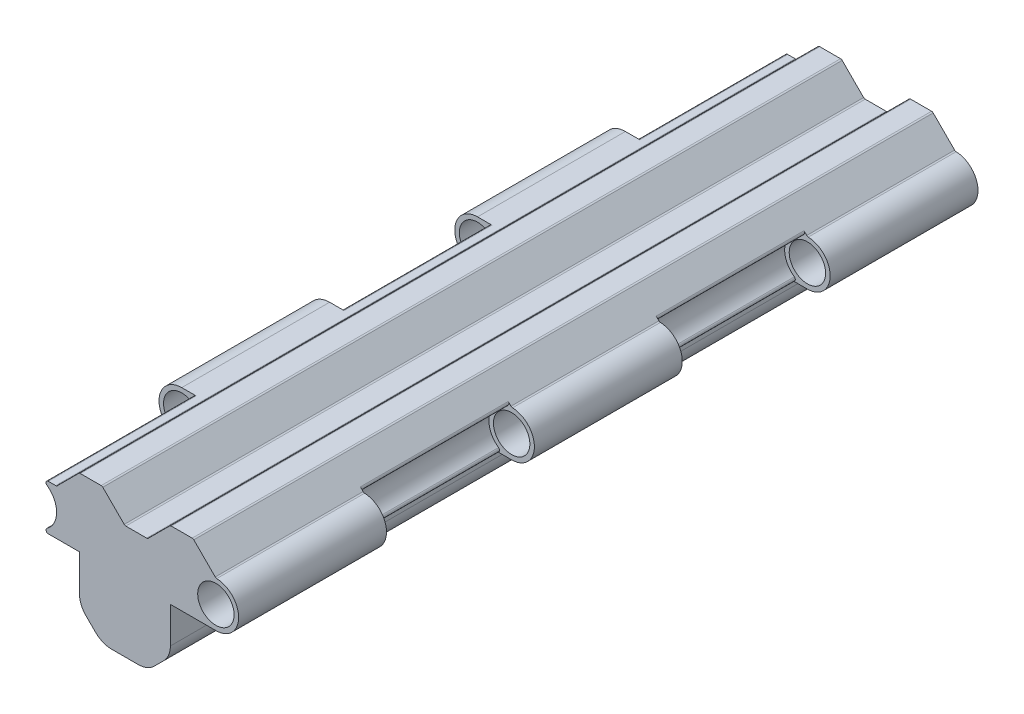
from build123d import *

# Parameters (mm, degrees)
BOSS_EXTRUDE1_DEPTH  = 32.5
CHAMFER1_SIZE        = 1
FILLET1_R            = 1
BOSS_EXTRUDE7_DEPTH  = 32.5
SKETCH3_R            = 0.9999999999999979
BOSS_EXTRUDE9_DEPTH  = 6.5
LPATTERN2_COUNT      = 3
LPATTERN2_PITCH      = 13
SKETCH5_R            = 1.0000000000000002
BOSS_EXTRUDE10_DEPTH = 6.5
LPATTERN3_COUNT      = 2
LPATTERN3_PITCH      = 13
FILLET2_R            = 0.1
M2_TAPPED_HOLE1_D    = 1.6
FILLET3_R            = 0.1


with BuildPart() as part:
    # Sketch1 → Boss-Extrude1 (new body)
    with BuildSketch(Plane.XY):
        Polygon((0, 0), (4, 0), (3.9999999999999982, 4), (-1.73e-15, 4), align=None)
    extrude(amount=BOSS_EXTRUDE1_DEPTH)

    # Chamfer1
    chamfer1_edges = [part.edges().sort_by_distance(p)[0] for p in [
        (4, 0, 16.25),
        (0, 0, 16.25),
    ]]
    chamfer(chamfer1_edges, length=CHAMFER1_SIZE)

    # Fillet1
    fillet1_edges = [part.edges().sort_by_distance(p)[0] for p in [
        (3, 0, 16.25),
        (1, 0, 16.25),
        (-4.3e-16, 1, 16.25),
        (3.9999999999999996, 1, 16.25),
    ]]
    fillet(fillet1_edges, radius=FILLET1_R)

    # Sketch2 → Boss-Extrude7 (add)
    with BuildSketch(Plane.XY.offset(32.5)):
        with BuildLine():
            Line((-1.73e-15, 3), (-2, 2.9999999999999996))
            ThreePointArc((-2, 2.9999999999999996), (-1.0000000000000009, 4), (-2, 4.999999999999999))
            Line((-2, 4.999999999999999), (-1.0000000000000009, 4.999999999999999))
            Line((-1.0000000000000009, 4.999999999999999), (-1.74e-15, 6.000000000000002))
            Line((-1.74e-15, 6.000000000000002), (1, 6))
            Line((1, 6), (2.000000000000004, 4.999999999999999))
            Line((2.000000000000004, 4.999999999999999), (3.000000000000002, 4.999999999999997))
            Line((3.000000000000002, 4.999999999999997), (4.000000000000002, 6))
            Line((4.000000000000002, 6), (5.0000000000000036, 5.999999999999998))
            Line((5.0000000000000036, 5.999999999999998), (6.000000000000008, 4.999999999999997))
            ThreePointArc((6.000000000000008, 4.999999999999997), (5.000000000000009, 3.9999999999999982), (6.000000000000008, 3))
            Line((6.000000000000008, 3), (-1.73e-15, 3))
        make_face()
    extrude(amount=-BOSS_EXTRUDE7_DEPTH)

    # Sketch3 → Boss-Extrude9 (add)
    with BuildSketch(Plane.XY.offset(32.5)):
        with Locations((6.000000000000008, 3.9999999999999982)):
            Circle(SKETCH3_R)
    boss_extrude9 = extrude(amount=-BOSS_EXTRUDE9_DEPTH)

    # LPattern2: Boss-Extrude9 ×3
    with Locations(*[(0, 0, -i * LPATTERN2_PITCH) for i in range(1, LPATTERN2_COUNT)]):
        add(boss_extrude9)

    # Sketch5 → Boss-Extrude10 (add)
    with BuildSketch(Plane.XY.offset(26.000000000000004)):
        with Locations((-2, 4)):
            Circle(SKETCH5_R)
    boss_extrude10 = extrude(amount=-BOSS_EXTRUDE10_DEPTH)

    # LPattern3: Boss-Extrude10 ×2
    with Locations(*[(0, 0, -i * LPATTERN3_PITCH) for i in range(1, LPATTERN3_COUNT)]):
        add(boss_extrude10)

    # Fillet2
    fillet2_edges = [part.edges().sort_by_distance(p)[0] for p in [
        (6.000000000000008, 4.999999999999998, 9.75),
        (6.000000000000008, 3, 9.75),
        (-2, 4.999999999999999, 29.25),
        (-2, 2.9999999999999996, 29.25),
        (-2, 4.999999999999999, 16.250000000000004),
        (-2, 2.9999999999999996, 16.250000000000004),
        (-2, 2.9999999999999996, 3.25),
        (-2, 4.999999999999999, 3.25),
        (6.000000000000008, 4.999999999999998, 22.75),
        (6.000000000000008, 3, 22.75),
    ]]
    fillet(fillet2_edges, radius=FILLET2_R)

    # M2 Tapped Hole1 (through all)
    with Locations(Plane(origin=(0, 0, 0), x_dir=(-1, 0, 0), z_dir=(0, 0, -1))):
        with Locations((-6, 4), (2, 4)):
            Hole(M2_TAPPED_HOLE1_D / 2)

    # Fillet3
    fillet3_edges = [part.edges().sort_by_distance(p)[0] for p in [
        (6.000000000000008, 4.999999999999998, 3.25),
        (-1.0000000000000009, 4.999999999999999, 16.25),
        (-1.74e-15, 6.000000000000002, 16.25),
        (1, 6, 16.25),
        (2.000000000000004, 4.999999999999999, 16.25),
        (3.000000000000002, 4.999999999999997, 16.25),
        (4.000000000000002, 6, 16.25),
        (5.0000000000000036, 5.999999999999998, 16.25),
        (6.000000000000008, 4.999999999999998, 29.25),
        (6.000000000000008, 4.999999999999998, 16.25),
    ]]
    fillet(fillet3_edges, radius=FILLET3_R)


solid = part.part
